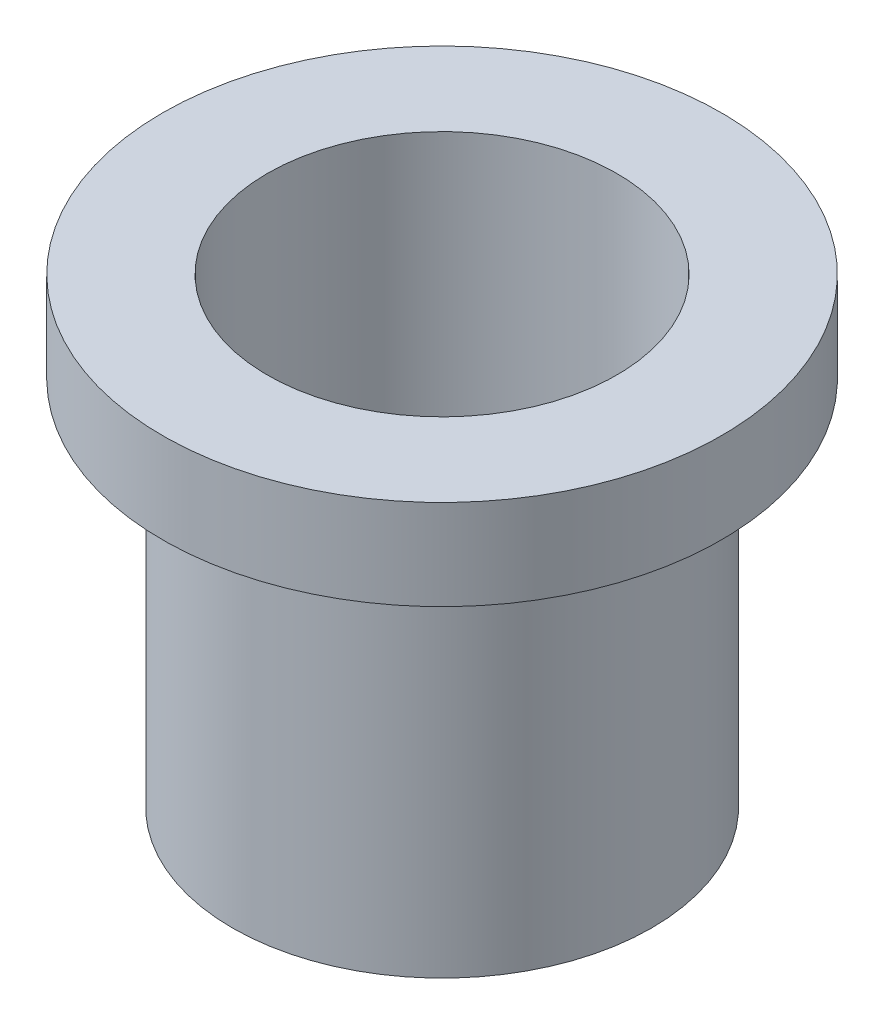
from build123d import *


with BuildPart() as part:
    # Sketch1 → Revolve3 (revolve)
    with BuildSketch(Plane.XY):
        Polygon((9.525, 0), (12.7, 0), (12.7, 4.1), (7.9375, 4.1), (7.9375, -16.86), (9.525, -16.86), align=None)
    revolve(axis=Axis((0, 35.765798189, 0), (0, -1, 0)))


solid = part.part
